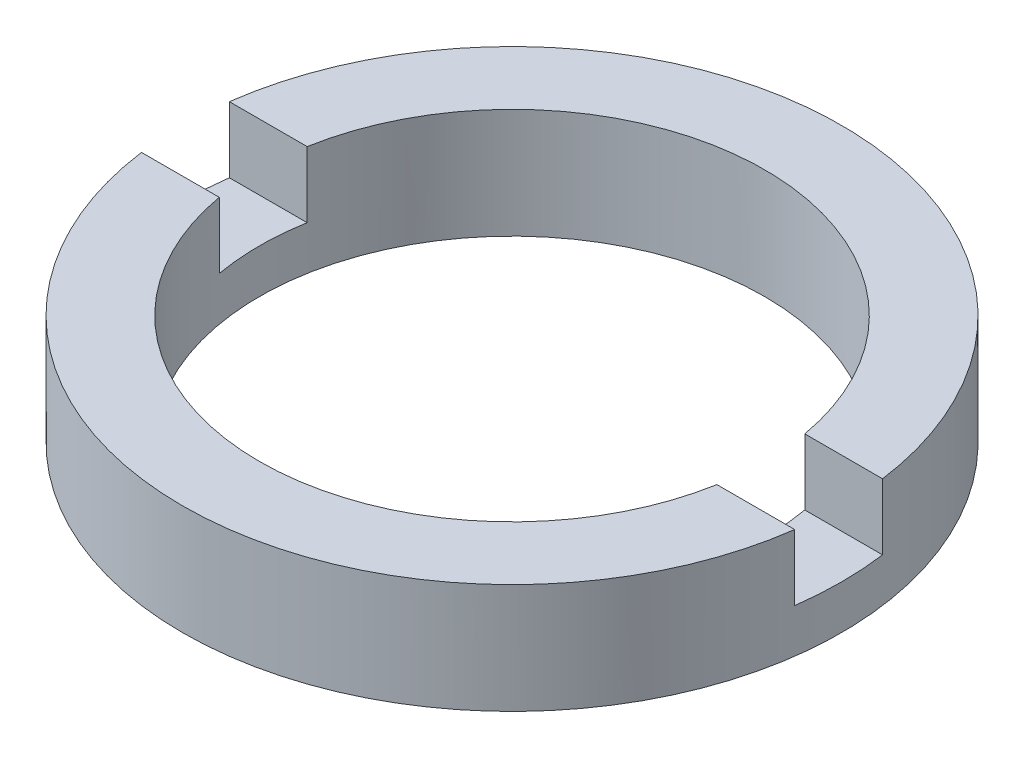
from build123d import *

# Parameters (mm, degrees)
SKETCH_1_W          = 1.75
SKETCH_1_H          = 2.5
SKETCH_2_W          = 53.705080546
SKETCH_2_H          = 2
CUT_EXTRUDE_1_DEPTH = 1.5


with BuildPart() as part:
    # 草图1 → 旋转1 (revolve)
    with BuildSketch(Plane.XY, mode=Mode.PRIVATE) as revolve_1_sk:
        with Locations((6.625, -3.214249787)):
            Rectangle(SKETCH_1_W, SKETCH_1_H)
    revolve(revolve_1_sk.sketch.rotate(Axis((0, 56.260842627, 0), (0, -1, 0)), 90), axis=Axis((0, 56.260842627, 0), (0, -1, 0)))  # turned: the seam where the file's is

    # 草图2 → 切除-拉伸1 (cut)
    with BuildSketch(Plane(origin=(0, -1.964249787, 0), x_dir=(1, 0, 0), z_dir=(0, 1, 0))):
        Rectangle(SKETCH_2_W, SKETCH_2_H)
    extrude(amount=-CUT_EXTRUDE_1_DEPTH, mode=Mode.SUBTRACT)


solid = part.part
